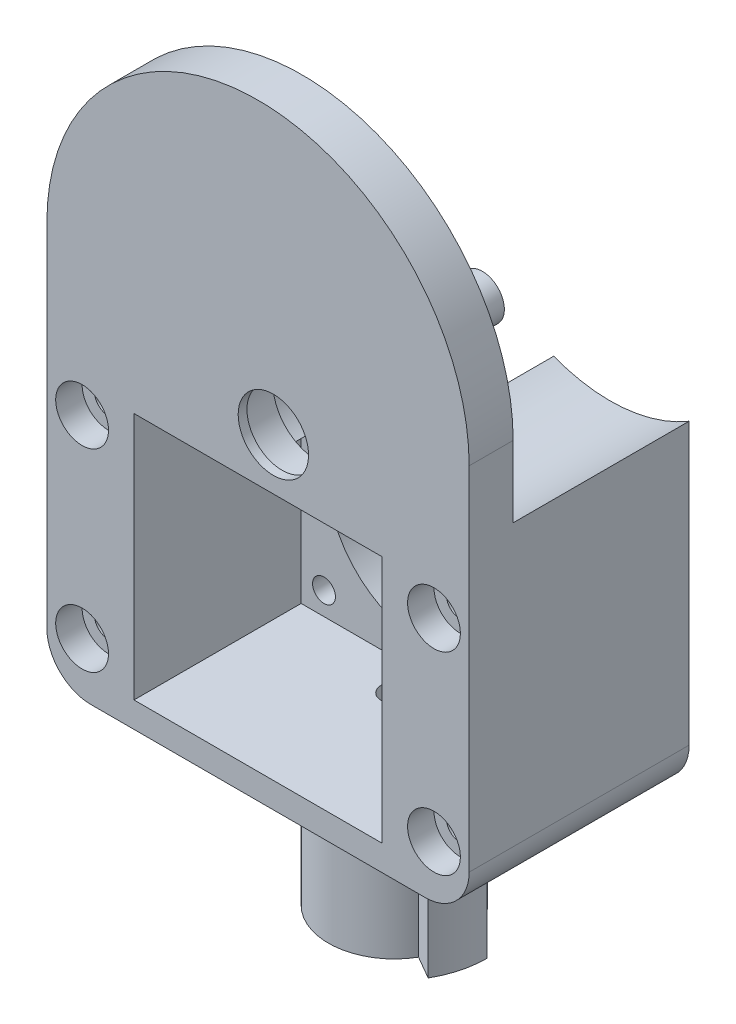
from build123d import *

# Parameters (mm, degrees)
EXTRUDE_1_DEPTH      = 25
SKETCH_3_W           = 28.2
SKETCH_3_H           = 28.2
CUT_EXTRUDE_1_DEPTH  = 19
SKETCH_4_R           = 11.1
CUT_EXTRUDE_2_DEPTH  = 26
CUT_EXTRUDE_3_DEPTH  = 20
SKETCH_11_R          = 3
EXTRUDE_2_DEPTH      = 0.5
SKETCH_12_R          = 2.5
EXTRUDE_3_DEPTH      = 5
SKETCH_13_R          = 5.05
CUT_EXTRUDE_6_DEPTH  = 4
SKETCH_14_R          = 4
CUT_EXTRUDE_7_DEPTH  = 2
SKETCH_15_R          = 1.6
CUT_EXTRUDE_8_DEPTH  = 26
SKETCH_16_R          = 3
CUT_EXTRUDE_9_DEPTH  = 3
SKETCH_17_R          = 1.3
CUT_EXTRUDE_10_DEPTH = 7
SKETCH_18_R          = 2.5
CUT_EXTRUDE_11_DEPTH = 2.5
FILLET_1_R           = 5
SKETCH_19_R          = 7.5
EXTRUDE_4_DEPTH      = 18
CUT_EXTRUDE_12_DEPTH = 18
SKETCH_21_R          = 1.5
CUT_EXTRUDE_13_DEPTH = 10
EXTRUDE_5_DEPTH      = 18
SKETCH_23_R          = 2
CUT_EXTRUDE_14_DEPTH = 8.4


with BuildPart() as part:
    # 草图1 → 凸台-拉伸1 (new body)
    with BuildSketch(Plane.XY):
        with BuildLine():
            Line((-24, 0), (-24, -45))
            Line((-24, -45), (24, -45))
            Line((24, -45), (24, 0))
            ThreePointArc((24, 0), (0, 24), (-24, 0))
        make_face()
    extrude(amount=EXTRUDE_1_DEPTH)

    # 草图3 → 切除-拉伸1 (cut)
    with BuildSketch(Plane.XY.offset(25)):
        with Locations((0, -28)):
            Rectangle(SKETCH_3_W, SKETCH_3_H)
    extrude(amount=-CUT_EXTRUDE_1_DEPTH, mode=Mode.SUBTRACT)

    # 草图4 → 切除-拉伸2 (cut, through all)
    with BuildSketch(Plane(origin=(0, 0, 0), x_dir=(-1, 0, 0), z_dir=(0, 0, -1))):
        with Locations((0, -28)):
            Circle(SKETCH_4_R)
    extrude(amount=-CUT_EXTRUDE_2_DEPTH, mode=Mode.SUBTRACT)

    # 草图8 → 切除-拉伸3 (cut)
    with BuildSketch(Plane(origin=(0, 0, 0), x_dir=(-1, 0, 0), z_dir=(0, 0, -1))):
        with BuildLine():
            Line((-24, 0), (-24, -8.109291107))
            ThreePointArc((-24, -8.109291107), (-16.458301288, -10.540093017), (-8.617628111, -9.395601202))
            ThreePointArc((-8.617628111, -9.395601202), (-0.85769165, -15.019882082), (5.242543421, -7.628246176))
            ThreePointArc((5.242543421, -7.628246176), (14.551350723, -10.595208108), (24, -8.109291107))
            Line((24, -8.109291107), (24, 0))
            ThreePointArc((24, 0), (0, 24), (-24, 0))
        make_face()
    extrude(amount=-CUT_EXTRUDE_3_DEPTH, mode=Mode.SUBTRACT)

    # 草图11 → 凸台-拉伸2 (add)
    with BuildSketch(Plane(origin=(0, 0, 20), x_dir=(-1, 0, 0), z_dir=(0, 0, -1))):
        with Locations((-15, 6.899039913)):
            Circle(SKETCH_11_R)
        with Locations((15, 6.899039913)):
            Circle(SKETCH_11_R)
    extrude(amount=EXTRUDE_2_DEPTH)

    # 草图12 → 凸台-拉伸3 (add)
    with BuildSketch(Plane(origin=(0, 0, 19.5), x_dir=(-1, 0, 0), z_dir=(0, 0, -1))):
        with Locations((-15, 6.899039913)):
            Circle(SKETCH_12_R)
        with Locations((15, 6.899039913)):
            Circle(SKETCH_12_R)
    extrude(amount=EXTRUDE_3_DEPTH)

    # 草图13 → 切除-拉伸6 (cut)
    with BuildSketch(Plane(origin=(0, 0, 20), x_dir=(-1, 0, 0), z_dir=(0, 0, -1))):
        with Locations((-1.743114855, -8.076106038)):
            Circle(SKETCH_13_R)
    extrude(amount=-CUT_EXTRUDE_6_DEPTH, mode=Mode.SUBTRACT)

    # 草图14 → 切除-拉伸7 (cut, through all)
    with BuildSketch(Plane(origin=(0, 0, 24), x_dir=(-1, 0, 0), z_dir=(0, 0, -1))):
        with Locations((-1.743114855, -8.076106038)):
            Circle(SKETCH_14_R)
    extrude(amount=-CUT_EXTRUDE_7_DEPTH, mode=Mode.SUBTRACT)

    # 草图15 → 切除-拉伸8 (cut, through all)
    with BuildSketch(Plane.XY.offset(25)):
        with Locations((-20, -39)):
            Circle(SKETCH_15_R)
        with Locations((-20, -17)):
            Circle(SKETCH_15_R)
        with Locations((20, -39)):
            Circle(SKETCH_15_R)
        with Locations((20, -17)):
            Circle(SKETCH_15_R)
    extrude(amount=-CUT_EXTRUDE_8_DEPTH, mode=Mode.SUBTRACT)

    # 草图16 → 切除-拉伸9 (cut)
    with BuildSketch(Plane.XY.offset(25)):
        with Locations((-20, -17)):
            Circle(SKETCH_16_R)
        with Locations((-20, -39)):
            Circle(SKETCH_16_R)
        with Locations((20, -17)):
            Circle(SKETCH_16_R)
        with Locations((20, -39)):
            Circle(SKETCH_16_R)
    extrude(amount=-CUT_EXTRUDE_9_DEPTH, mode=Mode.SUBTRACT)

    # 草图17 → 切除-拉伸10 (cut, through all)
    with BuildSketch(Plane.XY.offset(6)):
        with Locations((-11.5, -16.5)):
            Circle(SKETCH_17_R)
        with Locations((11.5, -16.5)):
            Circle(SKETCH_17_R)
        with Locations((11.5, -39.5)):
            Circle(SKETCH_17_R)
        with Locations((-11.5, -39.5)):
            Circle(SKETCH_17_R)
    extrude(amount=-CUT_EXTRUDE_10_DEPTH, mode=Mode.SUBTRACT)

    # 草图18 → 切除-拉伸11 (cut)
    with BuildSketch(Plane(origin=(0, 0, 0), x_dir=(-1, 0, 0), z_dir=(0, 0, -1))):
        with Locations((-11.5, -16.5)):
            Circle(SKETCH_18_R)
        with Locations((11.5, -16.5)):
            Circle(SKETCH_18_R)
        with Locations((-11.5, -39.5)):
            Circle(SKETCH_18_R)
        with Locations((11.5, -39.5)):
            Circle(SKETCH_18_R)
    extrude(amount=-CUT_EXTRUDE_11_DEPTH, mode=Mode.SUBTRACT)

    # 圆角1
    fillet_1_edges = [part.edges().sort_by_distance(p)[0] for p in [
        (24, -45, 12.5),
        (-24, -45, 12.5),
    ]]
    fillet(fillet_1_edges, radius=FILLET_1_R)

    # 草图19 → 凸台-拉伸4 (add)
    with BuildSketch(Plane.XZ.offset(45)):
        with Locations((0, 9.5)):
            Circle(SKETCH_19_R)
    extrude(amount=EXTRUDE_4_DEPTH)

    # 草图20 → 切除-拉伸12 (cut)
    with BuildSketch(Plane.XZ.offset(63)):
        with BuildLine():
            Line((-1.446547614, 7.4), (1.446547614, 7.4))
            ThreePointArc((1.446547614, 7.4), (0, 12.05), (-1.446547614, 7.4))
        make_face()
    extrude(amount=-CUT_EXTRUDE_12_DEPTH, mode=Mode.SUBTRACT)

    # 草图21 → 切除-拉伸13 (cut)
    with BuildSketch(Plane.XZ.offset(45)):
        with Locations((0, 9.5)):
            Circle(SKETCH_21_R)
    extrude(amount=-CUT_EXTRUDE_13_DEPTH, mode=Mode.SUBTRACT)

    # 草图22 → 凸台-拉伸5 (add)
    with BuildSketch(Plane.XZ.offset(45)):
        with BuildLine():
            Line((7.5, 9.5), (10.5, 9.5))
            ThreePointArc((10.5, 9.5), (10.142221176, 12.217599974), (9.09326674, 14.75))
            Line((9.09326674, 14.75), (6.495190528, 13.25))
            ThreePointArc((6.495190528, 13.25), (7.244443697, 11.441142838), (7.5, 9.5))
        make_face()
    extrude(amount=EXTRUDE_5_DEPTH)

    # 草图23 → 切除-拉伸14 (cut, through all)
    with BuildSketch(Plane.XY.offset(7.4)):
        with Locations((0, -53)):
            Circle(SKETCH_23_R)
    extrude(amount=-CUT_EXTRUDE_14_DEPTH, mode=Mode.SUBTRACT)


solid = part.part
